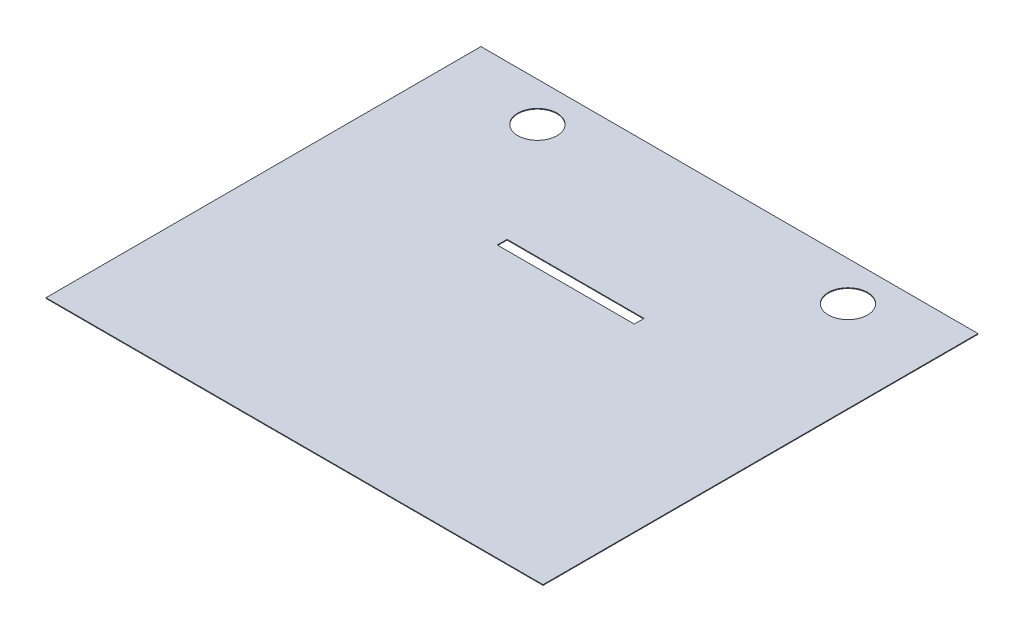
from build123d import *

# Parameters (mm, degrees)
SKETCH2_W           = 50.8
SKETCH2_H           = 44.45
SKETCH2_R           = 2.001280135
SKETCH2_R_2         = 2
SKETCH2_W_2         = 14
SKETCH2_H_2         = 1
BOSS_EXTRUDE3_DEPTH = 0.07


with BuildPart() as part:
    # Sketch2 → Boss-Extrude3 (new body)
    with BuildSketch(Plane(origin=(0, 0, 0), x_dir=(1, 0, 0), z_dir=(0, 1, 0))):
        with Locations((25.4, 22.225)):
            Rectangle(SKETCH2_W, SKETCH2_H)
        with Locations((9.772683783, 40.45)):
            Circle(SKETCH2_R, mode=Mode.SUBTRACT)
        with Locations((41.512867403, 40.45)):
            Circle(SKETCH2_R_2, mode=Mode.SUBTRACT)
        with Locations((25.4, 28.225)):
            Rectangle(SKETCH2_W_2, SKETCH2_H_2, mode=Mode.SUBTRACT)
    extrude(amount=-BOSS_EXTRUDE3_DEPTH)


solid = part.part
